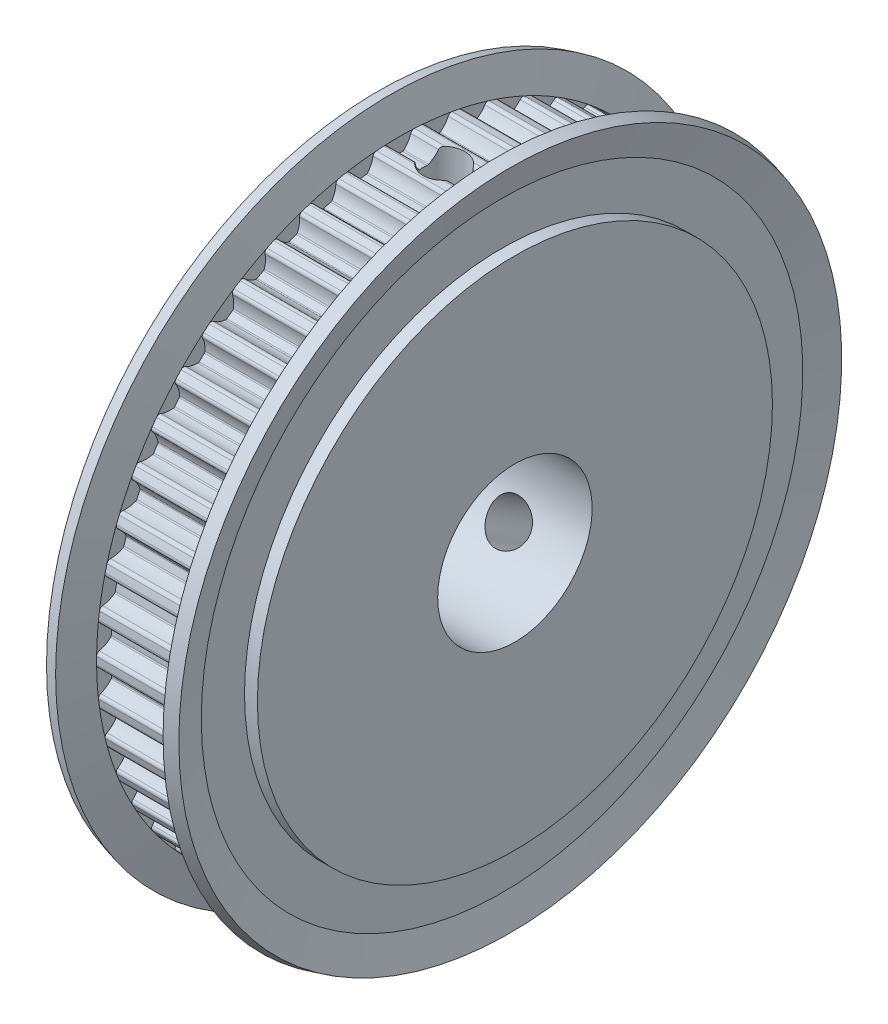
from build123d import *

# Parameters (mm, degrees)
SKETCH_2_W          = 11
SKETCH_2_H          = 6
SKETCH_3_R          = 28.49
CUT_EXTRUDE_1_DEPTH = 7
SKETCH_4_W          = 1.621
SKETCH_4_H          = 23.49


with BuildPart() as part:
    # ｽｹｯﾁ1 → 回転1 (revolve)
    with BuildSketch(Plane.XY):
        Polygon((0, 0), (0, 20), (1, 20), (1, 23.358347502), (0.361521701, 25.741180955), (1.327447527, 26), (2, 23.49), (9, 23.49), (9.672552473, 26), (10.638478299, 25.741180955), (10, 23.358347502), (10, 20), (11, 20), (11, 0), align=None)
    revolve(axis=Axis((11, 0, 0), (-1, 0, 0)))

    # ｽｹｯﾁ2 → ｶｯﾄ - 回転1 (revolve, cut)
    with BuildSketch(Plane.XY):
        with Locations((5.5, 3)):
            Rectangle(SKETCH_2_W, SKETCH_2_H)
    revolve(axis=Axis((11, 0, 0), (-1, 0, 0)), mode=Mode.SUBTRACT)

    # ｽｹｯﾁ3 → ｶｯﾄ - 押し出し1 (cut)
    with BuildSketch(Plane(origin=(2, 0, 0), x_dir=(0, 0, -1), z_dir=(1, 0, 0))):
        Circle(SKETCH_3_R)
        with BuildLine():
            ThreePointArc((-23.488276086, 0.284581247), (-23.49, 7.6e-08), (-23.488276088, -0.284581095))
            ThreePointArc((-23.488276088, -0.284581095), (-23.427611694, -0.455260452), (-23.275160558, -0.553088173))
            ThreePointArc((-23.275160558, -0.553088173), (-22.80663919, -0.73407221), (-22.398920767, -1.027386346))
            ThreePointArc((-22.398920767, -1.027386346), (-22.365264934, -1.07380197), (-22.351481689, -1.129453992))
            ThreePointArc((-22.351481689, -1.129453992), (-22.335838193, -1.405251659), (-22.316791726, -1.680835229))
            ThreePointArc((-22.316791726, -1.680835229), (-22.32349116, -1.737776087), (-22.351064233, -1.788044062))
            ThreePointArc((-22.351064233, -1.788044062), (-22.718805667, -2.130146002), (-23.160949295, -2.368424227))
            ThreePointArc((-23.160949295, -2.368424227), (-23.299937204, -2.484587678), (-23.338731501, -2.661524359))
            ThreePointArc((-23.338731501, -2.661524359), (-23.304774343, -2.944077583), (-23.267396547, -3.226198681))
            ThreePointArc((-23.267396547, -3.226198681), (-23.185818714, -3.387928916), (-23.022308636, -3.465878042))
            ThreePointArc((-23.022308636, -3.465878042), (-22.534798384, -3.586713668), (-22.093532933, -3.826614266))
            ThreePointArc((-22.093532933, -3.826614266), (-22.054325066, -3.868445695), (-22.033675459, -3.921931385))
            ThreePointArc((-22.033675459, -3.921931385), (-21.983588671, -4.19359382), (-21.930152576, -4.464617342))
            ThreePointArc((-21.930152576, -4.464617342), (-21.9296627, -4.521948705), (-21.950718076, -4.575275962))
            ThreePointArc((-21.950718076, -4.575275962), (-22.272683016, -4.960770544), (-22.681476025, -5.252585162))
            ThreePointArc((-22.681476025, -5.252585162), (-22.804808832, -5.385252434), (-22.821121178, -5.56565613))
            ThreePointArc((-22.821121178, -5.56565613), (-22.752018473, -5.841725378), (-22.679576263, -6.116937186))
            ThreePointArc((-22.679576263, -6.116937186), (-22.578371522, -6.267167716), (-22.406381154, -6.324008944))
            ThreePointArc((-22.406381154, -6.324008944), (-21.907570346, -6.382790509), (-21.439716888, -6.565494193))
            ThreePointArc((-21.439716888, -6.565494193), (-21.395575318, -6.60208172), (-21.368385004, -6.652557577))
            ThreePointArc((-21.368385004, -6.652557577), (-21.284644835, -6.915800334), (-21.197661844, -7.177989435))
            ThreePointArc((-21.197661844, -7.177989435), (-21.189990306, -7.234807325), (-21.204195976, -7.290353018))
            ThreePointArc((-21.204195976, -7.290353018), (-21.475306844, -7.713160768), (-21.844302329, -8.053909691))
            ThreePointArc((-21.844302329, -8.053909691), (-21.950035002, -8.200988541), (-21.943608142, -8.38201418))
            ThreePointArc((-21.943608142, -8.38201418), (-21.840449681, -8.647245674), (-21.734085513, -8.911207939))
            ThreePointArc((-21.734085513, -8.911207939), (-21.614849923, -9.047569538), (-21.437091656, -9.082406447))
            ThreePointArc((-21.437091656, -9.082406447), (-20.934846832, -9.078206931), (-20.44778369, -9.200832358))
            ThreePointArc((-20.44778369, -9.200832358), (-20.399404562, -9.231598975), (-20.366102353, -9.278268962))
            ThreePointArc((-20.366102353, -9.278268962), (-20.250029434, -9.528940545), (-20.130871323, -9.778160347))
            ThreePointArc((-20.130871323, -9.778160347), (-20.116139107, -9.833568714), (-20.12327104, -9.890456856))
            ThreePointArc((-20.12327104, -9.890456856), (-20.339252255, -10.343909841), (-20.662630936, -10.728219253))
            ThreePointArc((-20.662630936, -10.728219253), (-20.749096008, -10.887390161), (-20.720031296, -11.066182859))
            ThreePointArc((-20.720031296, -11.066182859), (-20.58444395, -11.31639374), (-20.445835251, -11.564943618))
            ThreePointArc((-20.445835251, -11.564943618), (-20.310449229, -11.685285784), (-20.129726417, -11.697568975))
            ThreePointArc((-20.129726417, -11.697568975), (-19.631968282, -11.630454605), (-19.133376738, -11.691067895))
            ThreePointArc((-19.133376738, -11.691067895), (-19.081523014, -11.715528397), (-19.042634103, -11.757656503))
            ThreePointArc((-19.042634103, -11.757656503), (-18.896058973, -11.991803672), (-18.746604935, -12.22412383))
            ThreePointArc((-18.746604935, -12.22412383), (-18.725044378, -12.277248844), (-18.724990097, -12.33458227))
            ThreePointArc((-18.724990097, -12.33458227), (-18.882435506, -12.811529272), (-19.15509751, -13.233338389))
            ThreePointArc((-19.15509751, -13.233338389), (-19.220931375, -13.402091139), (-19.169687174, -13.575831232))
            ThreePointArc((-19.169687174, -13.575831232), (-19.003809098, -13.807075713), (-18.835141669, -14.036293611))
            ThreePointArc((-18.835141669, -14.036293611), (-18.685740389, -14.138718157), (-18.504903367, -14.128253853))
            ThreePointArc((-18.504903367, -14.128253853), (-18.019481823, -13.999283057), (-17.51722492, -13.996928319))
            ThreePointArc((-17.51722492, -13.996928319), (-17.462714412, -14.014696957), (-17.418852136, -14.051618777))
            ThreePointArc((-17.418852136, -14.051618777), (-17.244086373, -14.265548891), (-17.066693389, -14.477305577))
            ThreePointArc((-17.066693389, -14.477305577), (-17.038644513, -14.527309433), (-17.031404876, -14.584183967))
            ThreePointArc((-17.031404876, -14.584183967), (-17.127831473, -15.077103239), (-17.345476754, -15.529759874))
            ThreePointArc((-17.345476754, -15.529759874), (-17.389641171, -15.705433128), (-17.317025639, -15.871380628))
            ThreePointArc((-17.317025639, -15.871380628), (-17.123472942, -16.080011642), (-16.927406885, -16.286282453))
            ThreePointArc((-16.927406885, -16.286282453), (-16.766346479, -16.369174405), (-16.588246937, -16.336127727))
            ThreePointArc((-16.588246937, -16.336127727), (-16.122817409, -16.147334452), (-15.624816074, -16.082048801))
            ThreePointArc((-15.624816074, -16.082048801), (-15.568508401, -16.092845351), (-15.520364466, -16.123978629))
            ThreePointArc((-15.520364466, -16.123978629), (-15.320164231, -16.314317882), (-15.117629892, -16.502171567))
            ThreePointArc((-15.117629892, -16.502171567), (-15.083535048, -16.548265665), (-15.069224227, -16.603784352))
            ThreePointArc((-15.069224227, -16.603784352), (-15.103111302, -17.104902272), (-15.262307467, -17.581267768))
            ThreePointArc((-15.262307467, -17.581267768), (-15.284105938, -17.761091056), (-15.191264264, -17.91662887))
            ThreePointArc((-15.191264264, -17.91662887), (-14.973089389, -18.099356181), (-14.752716783, -18.279426892))
            ThreePointArc((-14.752716783, -18.279426892), (-14.582537271, -18.341478995), (-14.409983943, -18.286371108))
            ThreePointArc((-14.409983943, -18.286371108), (-13.971886538, -18.040732737), (-13.485994554, -17.913545765))
            ThreePointArc((-13.485994554, -17.913545765), (-13.428777718, -17.917199959), (-13.377111377, -17.942053706))
            ThreePointArc((-13.377111377, -17.942053706), (-13.154633946, -18.105800334), (-12.930152342, -18.266788454))
            ThreePointArc((-12.930152342, -18.266788454), (-12.890549221, -18.308245872), (-12.869392909, -18.361533162))
            ThreePointArc((-12.869392909, -18.361533162), (-12.840206048, -18.86294679), (-12.938442475, -19.355508567))
            ThreePointArc((-12.938442475, -19.355508567), (-12.937531224, -19.536645967), (-12.825927577, -19.679321172))
            ThreePointArc((-12.825927577, -19.679321172), (-12.586571271, -19.833263061), (-12.345367525, -19.98429385))
            ThreePointArc((-12.345367525, -19.98429385), (-12.168752738, -20.024527505), (-12.004466895, -19.948227493))
            ThreePointArc((-12.004466895, -19.948227493), (-11.60061067, -19.649617889), (-11.134490843, -19.462535411))
            ThreePointArc((-11.134490843, -19.462535411), (-11.077267187, -19.45898962), (-11.022893251, -19.477171879))
            ThreePointArc((-11.022893251, -19.477171879), (-10.781647226, -19.611743499), (-10.538758565, -19.743327174))
            ThreePointArc((-10.538758565, -19.743327174), (-10.494271733, -19.779494103), (-10.466603577, -19.829709619))
            ThreePointArc((-10.466603577, -19.829709619), (-10.374803072, -20.323511365), (-10.410530515, -20.824501433))
            ThreePointArc((-10.410530515, -20.824501433), (-10.386923914, -21.004096301), (-10.25831835, -21.131658823))
            ThreePointArc((-10.25831835, -21.131658823), (-10.001555406, -21.254387535), (-9.743324446, -21.373996555))
            ThreePointArc((-9.743324446, -21.373996555), (-9.563059705, -21.391777253), (-9.409632232, -21.295488414))
            ThreePointArc((-9.409632232, -21.295488414), (-9.046386241, -20.94861683), (-8.607389561, -20.704589248))
            ThreePointArc((-8.607389561, -20.704589248), (-8.551061536, -20.69389939), (-8.494837513, -20.705123415))
            ThreePointArc((-8.494837513, -20.705123415), (-8.238627489, -20.808397754), (-7.98116227, -20.908501831))
            ThreePointArc((-7.98116227, -20.908501831), (-7.932493314, -20.938807892), (-7.898749657, -20.985159701))
            ThreePointArc((-7.898749657, -20.985159701), (-7.745783254, -21.463562022), (-7.718438271, -21.965079472))
            ThreePointArc((-7.718438271, -21.965079472), (-7.672508609, -22.140299489), (-7.528929315, -22.250737592))
            ThreePointArc((-7.528929315, -22.250737592), (-7.258809037, -22.34031762), (-6.98762332, -22.426618567))
            ThreePointArc((-6.98762332, -22.426618567), (-6.806551508, -22.421665896), (-6.666402048, -22.306906762))
            ThreePointArc((-6.666402048, -22.306906762), (-6.349494892, -21.917243564), (-5.94454459, -21.620119337))
            ThreePointArc((-5.94454459, -21.620119337), (-5.890000528, -21.602454004), (-5.832813113, -21.606542787))
            ThreePointArc((-5.832813113, -21.606542787), (-5.565679675, -21.676891146), (-5.297698278, -21.743936924))
            ThreePointArc((-5.297698278, -21.743936924), (-5.245614737, -21.767904173), (-5.206327738, -21.809661279))
            ThreePointArc((-5.206327738, -21.809661279), (-4.994607809, -22.265119483), (-4.904621644, -22.759255086))
            ThreePointArc((-4.904621644, -22.759255086), (-4.83709326, -22.927336928), (-4.680804567, -23.018908936))
            ThreePointArc((-4.680804567, -23.018908936), (-4.401586913, -23.073927551), (-4.1217232, -23.125559406))
            ThreePointArc((-4.1217232, -23.125559406), (-3.942699928, -23.097951473), (-3.818038721, -22.966531864))
            ThreePointArc((-3.818038721, -22.966531864), (-3.55246822, -22.540222276), (-3.187950609, -22.19468723))
            ThreePointArc((-3.187950609, -22.19468723), (-3.136050699, -22.170325013), (-3.078801766, -22.167214071))
            ThreePointArc((-3.078801766, -22.167214071), (-2.804957934, -22.203526994), (-2.530686755, -22.236457104))
            ThreePointArc((-2.530686755, -22.236457104), (-2.476009826, -22.253707525), (-2.431798915, -22.29021148))
            ThreePointArc((-2.431798915, -22.29021148), (-2.164664413, -22.715542715), (-2.013456204, -23.194503652))
            ThreePointArc((-2.013456204, -23.194503652), (-1.925394058, -23.352796569), (-1.75886073, -23.424058336))
            ThreePointArc((-1.75886073, -23.424058336), (-1.474949132, -23.443647862), (-1.190821043, -23.45979636))
            ThreePointArc((-1.190821043, -23.45979636), (-1.016669614, -23.409968558), (-0.909462643, -23.263961039))
            ThreePointArc((-0.909462643, -23.263961039), (-0.699417006, -22.807728222), (-0.381080752, -22.419231654))
            ThreePointArc((-0.381080752, -22.419231654), (-0.332643482, -22.388556754), (-0.276235875, -22.378295148))
            ThreePointArc((-0.276235875, -22.378295148), (0, -22.38), (0.276235875, -22.378295148))
            ThreePointArc((0.276235875, -22.378295148), (0.332643535, -22.388556775), (0.381080835, -22.419231733))
            ThreePointArc((0.381080835, -22.419231733), (0.699417036, -22.807728271), (0.909462643, -23.263961039))
            ThreePointArc((0.909462643, -23.263961039), (1.016669756, -23.409968656), (1.190821387, -23.459796342))
            ThreePointArc((1.190821387, -23.459796342), (1.474949475, -23.44364784), (1.758861073, -23.42405831))
            ThreePointArc((1.758861073, -23.42405831), (1.925394186, -23.352796454), (2.013456204, -23.194503652))
            ThreePointArc((2.013456204, -23.194503652), (2.164664436, -22.715542665), (2.431798985, -22.290211395))
            ThreePointArc((2.431798985, -22.290211395), (2.476009727, -22.253707579), (2.53068642, -22.236457142))
            ThreePointArc((2.53068642, -22.236457142), (2.804957767, -22.203527015), (3.078801766, -22.167214071))
            ThreePointArc((3.078801766, -22.167214071), (3.13605076, -22.170325029), (3.187950712, -22.194687305))
            ThreePointArc((3.187950712, -22.194687305), (3.55246826, -22.540222325), (3.818038721, -22.966531864))
            ThreePointArc((3.818038721, -22.966531864), (3.94270008, -23.097951553), (4.121723539, -23.125559346))
            ThreePointArc((4.121723539, -23.125559346), (4.401587249, -23.073927487), (4.680804899, -23.018908868))
            ThreePointArc((4.680804899, -23.018908868), (4.83709337, -22.927336799), (4.904621644, -22.759255086))
            ThreePointArc((4.904621644, -22.759255086), (4.994607826, -22.26511943), (5.206327797, -21.809661185))
            ThreePointArc((5.206327797, -21.809661185), (5.245614783, -21.767904141), (5.297698278, -21.743936924))
            ThreePointArc((5.297698278, -21.743936924), (5.565679675, -21.676891146), (5.832813113, -21.606542787))
            ThreePointArc((5.832813113, -21.606542787), (5.890000585, -21.602454011), (5.944544691, -21.620119392))
            ThreePointArc((5.944544691, -21.620119392), (6.349494934, -21.917243603), (6.666402048, -22.306906762))
            ThreePointArc((6.666402048, -22.306906762), (6.806551674, -22.421665958), (6.987623659, -22.426618461))
            ThreePointArc((6.987623659, -22.426618461), (7.258809367, -22.340317513), (7.528929636, -22.250737483))
            ThreePointArc((7.528929636, -22.250737483), (7.672508702, -22.140299347), (7.718438271, -21.965079472))
            ThreePointArc((7.718438271, -21.965079472), (7.745783265, -21.463561967), (7.898749704, -20.9851596))
            ThreePointArc((7.898749704, -20.9851596), (7.932493355, -20.938807854), (7.98116227, -20.908501831))
            ThreePointArc((7.98116227, -20.908501831), (8.238627489, -20.808397754), (8.494837513, -20.705123415))
            ThreePointArc((8.494837513, -20.705123415), (8.551061588, -20.69389939), (8.607389659, -20.704589287))
            ThreePointArc((8.607389659, -20.704589287), (9.046386283, -20.948616861), (9.409632232, -21.295488414))
            ThreePointArc((9.409632232, -21.295488414), (9.563059873, -21.391777293), (9.743324759, -21.373996412))
            ThreePointArc((9.743324759, -21.373996412), (10.001555715, -21.254387389), (10.258318655, -21.131658675))
            ThreePointArc((10.258318655, -21.131658675), (10.386923989, -21.004096149), (10.410530515, -20.824501433))
            ThreePointArc((10.410530515, -20.824501433), (10.374803075, -20.323511307), (10.466603613, -19.829709507))
            ThreePointArc((10.466603613, -19.829709507), (10.494271771, -19.779494057), (10.538758565, -19.743327174))
            ThreePointArc((10.538758565, -19.743327174), (10.781647226, -19.611743499), (11.022893251, -19.477171879))
            ThreePointArc((11.022893251, -19.477171879), (11.077267243, -19.458989612), (11.134490952, -19.46253544))
            ThreePointArc((11.134490952, -19.46253544), (11.600610719, -19.649617917), (12.004466895, -19.948227493))
            ThreePointArc((12.004466895, -19.948227493), (12.168752914, -20.024527523), (12.345367827, -19.984293663))
            ThreePointArc((12.345367827, -19.984293663), (12.586571564, -19.833262875), (12.825927861, -19.679320987))
            ThreePointArc((12.825927861, -19.679320987), (12.937531279, -19.536645807), (12.938442475, -19.355508567))
            ThreePointArc((12.938442475, -19.355508567), (12.840206044, -18.862946736), (12.869392929, -18.361533055))
            ThreePointArc((12.869392929, -18.361533055), (12.89054925, -18.308245827), (12.930152342, -18.266788454))
            ThreePointArc((12.930152342, -18.266788454), (13.154633946, -18.105800334), (13.377111377, -17.942053706))
            ThreePointArc((13.377111377, -17.942053706), (13.428777772, -17.917199944), (13.485994666, -17.913545779))
            ThreePointArc((13.485994666, -17.913545779), (13.97188659, -18.040732758), (14.409983943, -18.286371108))
            ThreePointArc((14.409983943, -18.286371108), (14.582537451, -18.341478992), (14.752717064, -18.279426666))
            ThreePointArc((14.752717064, -18.279426666), (14.973089474, -18.09935611), (15.191264159, -17.916628959))
            ThreePointArc((15.191264159, -17.916628959), (15.284105923, -17.761091123), (15.262307467, -17.581267768))
            ThreePointArc((15.262307467, -17.581267768), (15.103111293, -17.104902224), (15.069224233, -16.603784253))
            ThreePointArc((15.069224233, -16.603784253), (15.083535069, -16.54826562), (15.117629892, -16.502171567))
            ThreePointArc((15.117629892, -16.502171567), (15.320164108, -16.314317997), (15.520364223, -16.123978863))
            ThreePointArc((15.520364223, -16.123978863), (15.568508299, -16.092845392), (15.624816191, -16.082048801))
            ThreePointArc((15.624816191, -16.082048801), (16.122817465, -16.147334467), (16.588246937, -16.336127727))
            ThreePointArc((16.588246937, -16.336127727), (16.766346658, -16.369174379), (16.927407135, -16.286282193))
            ThreePointArc((16.927407135, -16.286282193), (17.123473018, -16.080011561), (17.317025545, -15.87138073))
            ThreePointArc((17.317025545, -15.87138073), (17.389641166, -15.705433186), (17.345476741, -15.529759855))
            ThreePointArc((17.345476741, -15.529759855), (17.127831452, -15.077103178), (17.03140487, -14.584183861))
            ThreePointArc((17.03140487, -14.584183861), (17.038644529, -14.527309382), (17.066693389, -14.477305577))
            ThreePointArc((17.066693389, -14.477305577), (17.244086373, -14.265548891), (17.418852136, -14.051618777))
            ThreePointArc((17.418852136, -14.051618777), (17.462714456, -14.014696932), (17.517225021, -13.996928307))
            ThreePointArc((17.517225021, -13.996928307), (18.019481873, -13.999283064), (18.504903367, -14.128253853))
            ThreePointArc((18.504903367, -14.128253853), (18.685740562, -14.138718108), (18.835141884, -14.036293321))
            ThreePointArc((18.835141884, -14.036293321), (19.003809164, -13.807075623), (19.169687095, -13.575831345))
            ThreePointArc((19.169687095, -13.575831345), (19.220931378, -13.402091219), (19.155097524, -13.233338406))
            ThreePointArc((19.155097524, -13.233338406), (18.882435489, -12.811529237), (18.724990077, -12.334582171))
            ThreePointArc((18.724990077, -12.334582171), (18.725044388, -12.277248794), (18.746604935, -12.22412383))
            ThreePointArc((18.746604935, -12.22412383), (18.896058973, -11.991803672), (19.042634103, -11.757656503))
            ThreePointArc((19.042634103, -11.757656503), (19.08152302, -11.715528392), (19.133376752, -11.691067892))
            ThreePointArc((19.133376752, -11.691067892), (19.631968289, -11.630454605), (20.129726417, -11.697568975))
            ThreePointArc((20.129726417, -11.697568975), (20.310449176, -11.685285807), (20.445835194, -11.564943719))
            ThreePointArc((20.445835194, -11.564943719), (20.584443886, -11.316393855), (20.720031227, -11.06618299))
            ThreePointArc((20.720031227, -11.06618299), (20.74909602, -10.887390234), (20.662630936, -10.728219253))
            ThreePointArc((20.662630936, -10.728219253), (20.339252224, -10.343909792), (20.123271004, -9.890456745))
            ThreePointArc((20.123271004, -9.890456745), (20.116139111, -9.833568655), (20.130871323, -9.778160347))
            ThreePointArc((20.130871323, -9.778160347), (20.250029434, -9.528940545), (20.366102353, -9.278268962))
            ThreePointArc((20.366102353, -9.278268962), (20.399404569, -9.231598969), (20.447783708, -9.200832351))
            ThreePointArc((20.447783708, -9.200832351), (20.934846841, -9.07820693), (21.437091656, -9.082406447))
            ThreePointArc((21.437091656, -9.082406447), (21.614849878, -9.047569564), (21.734085474, -8.911208034))
            ThreePointArc((21.734085474, -8.911208034), (21.840449634, -8.647245791), (21.943608089, -8.382014318))
            ThreePointArc((21.943608089, -8.382014318), (21.95003502, -8.2009886), (21.844302308, -8.053909676))
            ThreePointArc((21.844302308, -8.053909676), (21.475306798, -7.713160714), (21.204195927, -7.290352915))
            ThreePointArc((21.204195927, -7.290352915), (21.189990302, -7.234807268), (21.197661844, -7.177989435))
            ThreePointArc((21.197661844, -7.177989435), (21.284644835, -6.915800334), (21.368385004, -6.652557577))
            ThreePointArc((21.368385004, -6.652557577), (21.395575322, -6.602081715), (21.439716897, -6.565494187))
            ThreePointArc((21.439716897, -6.565494187), (21.907570351, -6.382790507), (22.406381154, -6.324008944))
            ThreePointArc((22.406381154, -6.324008944), (22.578371483, -6.267167746), (22.679576238, -6.11693728))
            ThreePointArc((22.679576238, -6.11693728), (22.752018443, -5.841725496), (22.821121143, -5.565656274))
            ThreePointArc((22.821121143, -5.565656274), (22.804808858, -5.385252491), (22.681476005, -5.252585151))
            ThreePointArc((22.681476005, -5.252585151), (22.272682965, -4.960770497), (21.950718013, -4.575275864))
            ThreePointArc((21.950718013, -4.575275864), (21.929662689, -4.521948648), (21.930152576, -4.464617342))
            ThreePointArc((21.930152576, -4.464617342), (21.983588671, -4.19359382), (22.033675459, -3.921931385))
            ThreePointArc((22.033675459, -3.921931385), (22.05432507, -3.868445689), (22.093532945, -3.826614258))
            ThreePointArc((22.093532945, -3.826614258), (22.53479839, -3.586713666), (23.022308636, -3.465878042))
            ThreePointArc((23.022308636, -3.465878042), (23.185818679, -3.387928949), (23.267396534, -3.226198776))
            ThreePointArc((23.267396534, -3.226198776), (23.304774328, -2.944077704), (23.338731485, -2.661524505))
            ThreePointArc((23.338731485, -2.661524505), (23.299937243, -2.484587741), (23.160949295, -2.368424227))
            ThreePointArc((23.160949295, -2.368424227), (22.718805623, -2.13014597), (22.351064164, -1.78804398))
            ThreePointArc((22.351064164, -1.78804398), (22.323491195, -1.737776196), (22.3167917, -1.680835565))
            ThreePointArc((22.3167917, -1.680835565), (22.335838182, -1.405251827), (22.351481689, -1.129453992))
            ThreePointArc((22.351481689, -1.129453992), (22.365264935, -1.073801967), (22.398920772, -1.027386341))
            ThreePointArc((22.398920772, -1.027386341), (22.806639193, -0.734072209), (23.275160558, -0.553088173))
            ThreePointArc((23.275160558, -0.553088173), (23.427611669, -0.455260484), (23.488276087, -0.284581175))
            ThreePointArc((23.488276087, -0.284581175), (23.49, 1.98e-07), (23.488276083, 0.284581572))
            ThreePointArc((23.488276083, 0.284581572), (23.427611546, 0.455260639), (23.275160558, 0.553088173))
            ThreePointArc((23.275160558, 0.553088173), (22.806639138, 0.734072239), (22.39892068, 1.027386427))
            ThreePointArc((22.39892068, 1.027386427), (22.365264909, 1.073802024), (22.351481689, 1.129453992))
            ThreePointArc((22.351481689, 1.129453992), (22.335838182, 1.405251827), (22.3167917, 1.680835565))
            ThreePointArc((22.3167917, 1.680835565), (22.323491214, 1.737776256), (22.351064244, 1.788044077))
            ThreePointArc((22.351064244, 1.788044077), (22.718805675, 2.130146007), (23.160949295, 2.368424227))
            ThreePointArc((23.160949295, 2.368424227), (23.299937222, 2.484587706), (23.338731494, 2.661524425))
            ThreePointArc((23.338731494, 2.661524425), (23.304774309, 2.944077853), (23.267396481, 3.226199153))
            ThreePointArc((23.267396481, 3.226199153), (23.185818543, 3.387929082), (23.022308636, 3.465878042))
            ThreePointArc((23.022308636, 3.465878042), (22.534798391, 3.586713665), (22.093532946, 3.826614257))
            ThreePointArc((22.093532946, 3.826614257), (22.05432507, 3.868445688), (22.033675459, 3.921931385))
            ThreePointArc((22.033675459, 3.921931385), (21.983588671, 4.19359382), (21.930152576, 4.464617342))
            ThreePointArc((21.930152576, 4.464617342), (21.9296627, 4.521948707), (21.950718078, 4.575275965))
            ThreePointArc((21.950718078, 4.575275965), (22.272683017, 4.960770545), (22.681476025, 5.252585162))
            ThreePointArc((22.681476025, 5.252585162), (22.804808848, 5.385252468), (22.82112116, 5.565656204))
            ThreePointArc((22.82112116, 5.565656204), (22.752018464, 5.841725415), (22.679576263, 6.116937186))
            ThreePointArc((22.679576263, 6.116937186), (22.578371522, 6.267167716), (22.406381154, 6.324008944))
            ThreePointArc((22.406381154, 6.324008944), (21.907570286, 6.382790524), (21.439716778, 6.565494252))
            ThreePointArc((21.439716778, 6.565494252), (21.395575279, 6.602081768), (21.368385004, 6.652557577))
            ThreePointArc((21.368385004, 6.652557577), (21.284644835, 6.915800334), (21.197661844, 7.177989435))
            ThreePointArc((21.197661844, 7.177989435), (21.189990306, 7.234807328), (21.204195978, 7.290353024))
            ThreePointArc((21.204195978, 7.290353024), (21.475306846, 7.713160771), (21.844302329, 8.053909691))
            ThreePointArc((21.844302329, 8.053909691), (21.950035013, 8.200988578), (21.943608115, 8.382014251))
            ThreePointArc((21.943608115, 8.382014251), (21.840449579, 8.647245931), (21.734085332, 8.91120838))
            ThreePointArc((21.734085332, 8.91120838), (21.614849717, 9.047569658), (21.437091656, 9.082406447))
            ThreePointArc((21.437091656, 9.082406447), (20.934846778, 9.078206937), (20.447783589, 9.200832397))
            ThreePointArc((20.447783589, 9.200832397), (20.399404523, 9.231599013), (20.366102353, 9.278268962))
            ThreePointArc((20.366102353, 9.278268962), (20.250029434, 9.528940545), (20.130871323, 9.778160347))
            ThreePointArc((20.130871323, 9.778160347), (20.116139106, 9.833568719), (20.123271043, 9.890456866))
            ThreePointArc((20.123271043, 9.890456866), (20.339252258, 10.343909846), (20.662630936, 10.728219253))
            ThreePointArc((20.662630936, 10.728219253), (20.749096014, 10.887390198), (20.720031261, 11.066182926))
            ThreePointArc((20.720031261, 11.066182926), (20.584443817, 11.316393982), (20.445835016, 11.564944033))
            ThreePointArc((20.445835016, 11.564944033), (20.310449009, 11.685285876), (20.129726417, 11.697568975))
            ThreePointArc((20.129726417, 11.697568975), (19.631968294, 11.630454605), (19.133376761, 11.691067889))
            ThreePointArc((19.133376761, 11.691067889), (19.081523024, 11.715528389), (19.042634103, 11.757656503))
            ThreePointArc((19.042634103, 11.757656503), (18.896059063, 11.991803529), (18.746605119, 12.224123547))
            ThreePointArc((18.746605119, 12.224123547), (18.725044409, 12.277248686), (18.7249901, 12.334582286))
            ThreePointArc((18.7249901, 12.334582286), (18.88243551, 12.811529279), (19.15509751, 13.233338389))
            ThreePointArc((19.15509751, 13.233338389), (19.220931376, 13.402091172), (19.169687136, 13.575831286))
            ThreePointArc((19.169687136, 13.575831286), (19.003809079, 13.80707574), (18.835141669, 14.036293611))
            ThreePointArc((18.835141669, 14.036293611), (18.685740389, 14.138718157), (18.504903367, 14.128253853))
            ThreePointArc((18.504903367, 14.128253853), (18.01948188, 13.999283065), (17.517225035, 13.996928305))
            ThreePointArc((17.517225035, 13.996928305), (17.462714462, 14.014696929), (17.418852136, 14.051618777))
            ThreePointArc((17.418852136, 14.051618777), (17.244086481, 14.265548761), (17.066693607, 14.47730532))
            ThreePointArc((17.066693607, 14.47730532), (17.038644566, 14.527309271), (17.031404876, 14.584183964))
            ThreePointArc((17.031404876, 14.584183964), (17.127831472, 15.077103237), (17.345476754, 15.529759874))
            ThreePointArc((17.345476754, 15.529759874), (17.389641168, 15.705433161), (17.317025594, 15.871380677))
            ThreePointArc((17.317025594, 15.871380677), (17.123472919, 16.080011666), (16.927406885, 16.286282453))
            ThreePointArc((16.927406885, 16.286282453), (16.766346479, 16.369174405), (16.588246937, 16.336127727))
            ThreePointArc((16.588246937, 16.336127727), (16.122817466, 16.147334467), (15.624816192, 16.082048801))
            ThreePointArc((15.624816192, 16.082048801), (15.568508456, 16.092845329), (15.520364466, 16.123978629))
            ThreePointArc((15.520364466, 16.123978629), (15.320164108, 16.314317997), (15.117629644, 16.502171795))
            ThreePointArc((15.117629644, 16.502171795), (15.083534975, 16.548265818), (15.069224227, 16.603784355))
            ThreePointArc((15.069224227, 16.603784355), (15.103111303, 17.104902274), (15.262307467, 17.581267768))
            ThreePointArc((15.262307467, 17.581267768), (15.284105932, 17.761091083), (15.19126422, 17.916628907))
            ThreePointArc((15.19126422, 17.916628907), (14.973089367, 18.099356199), (14.752716783, 18.279426892))
            ThreePointArc((14.752716783, 18.279426892), (14.582537271, 18.341478995), (14.409983943, 18.286371108))
            ThreePointArc((14.409983943, 18.286371108), (13.971886596, 18.04073276), (13.485994678, 17.913545781))
            ThreePointArc((13.485994678, 17.913545781), (13.428777778, 17.917199943), (13.377111377, 17.942053706))
            ThreePointArc((13.377111377, 17.942053706), (13.15463381, 18.105800433), (12.930152067, 18.266788649))
            ThreePointArc((12.930152067, 18.266788649), (12.890549134, 18.308246008), (12.869392912, 18.361533147))
            ThreePointArc((12.869392912, 18.361533147), (12.840206047, 18.862946782), (12.938442475, 19.355508567))
            ThreePointArc((12.938442475, 19.355508567), (12.937531209, 19.536646009), (12.825927502, 19.679321221))
            ThreePointArc((12.825927502, 19.679321221), (12.586571435, 19.833262957), (12.345367931, 19.984293599))
            ThreePointArc((12.345367931, 19.984293599), (12.168752975, 20.02452753), (12.004466895, 19.948227493))
            ThreePointArc((12.004466895, 19.948227493), (11.600610721, 19.649617918), (11.134490958, 19.462535441))
            ThreePointArc((11.134490958, 19.462535441), (11.077267246, 19.458989612), (11.022893251, 19.477171879))
            ThreePointArc((11.022893251, 19.477171879), (10.781647079, 19.611743581), (10.538758268, 19.743327333))
            ThreePointArc((10.538758268, 19.743327333), (10.494271632, 19.779494223), (10.466603584, 19.829709597))
            ThreePointArc((10.466603584, 19.829709597), (10.374803072, 20.323511354), (10.410530515, 20.824501433))
            ThreePointArc((10.410530515, 20.824501433), (10.386923872, 21.004096384), (10.258318182, 21.131658905))
            ThreePointArc((10.258318182, 21.131658905), (10.001555321, 21.254387574), (9.743324446, 21.373996555))
            ThreePointArc((9.743324446, 21.373996555), (9.563059705, 21.391777253), (9.409632232, 21.295488414))
            ThreePointArc((9.409632232, 21.295488414), (9.046386289, 20.948616865), (8.607389671, 20.704589292))
            ThreePointArc((8.607389671, 20.704589292), (8.551061595, 20.69389939), (8.494837513, 20.705123415))
            ThreePointArc((8.494837513, 20.705123415), (8.238627332, 20.808397816), (7.981161955, 20.908501951))
            ThreePointArc((7.981161955, 20.908501951), (7.932493198, 20.938808), (7.898749666, 20.985159682))
            ThreePointArc((7.898749666, 20.985159682), (7.745783256, 21.463562012), (7.718438271, 21.965079472))
            ThreePointArc((7.718438271, 21.965079472), (7.672508584, 22.140299526), (7.52892923, 22.25073762))
            ThreePointArc((7.52892923, 22.25073762), (7.258808994, 22.340317634), (6.98762332, 22.426618567))
            ThreePointArc((6.98762332, 22.426618567), (6.806551508, 22.421665896), (6.666402048, 22.306906762))
            ThreePointArc((6.666402048, 22.306906762), (6.349494938, 21.917243607), (5.944544701, 21.620119398))
            ThreePointArc((5.944544701, 21.620119398), (5.890000591, 21.602454012), (5.832813113, 21.606542787))
            ThreePointArc((5.832813113, 21.606542787), (5.565679838, 21.676891104), (5.297698606, 21.743936844))
            ThreePointArc((5.297698606, 21.743936844), (5.245614884, 21.767904068), (5.20632775, 21.80966126))
            ThreePointArc((5.20632775, 21.80966126), (4.994607812, 22.265119472), (4.904621644, 22.759255086))
            ThreePointArc((4.904621644, 22.759255086), (4.83709323, 22.927336961), (4.68080448, 23.018908954))
            ThreePointArc((4.68080448, 23.018908954), (4.401586869, 23.07392756), (4.1217232, 23.125559406))
            ThreePointArc((4.1217232, 23.125559406), (3.942699925, 23.097951472), (3.818038719, 22.966531859))
            ThreePointArc((3.818038719, 22.966531859), (3.55246826, 22.540222325), (3.187950716, 22.194687308))
            ThreePointArc((3.187950716, 22.194687308), (3.136050763, 22.170325029), (3.078801766, 22.167214071))
            ThreePointArc((3.078801766, 22.167214071), (2.804957934, 22.203526994), (2.530686755, 22.236457104))
            ThreePointArc((2.530686755, 22.236457104), (2.476009843, 22.253707516), (2.431798938, 22.290211451))
            ThreePointArc((2.431798938, 22.290211451), (2.164664421, 22.715542698), (2.013456204, 23.194503652))
            ThreePointArc((2.013456204, 23.194503652), (1.925394027, 23.352796597), (1.758860646, 23.424058342))
            ThreePointArc((1.758860646, 23.424058342), (1.474949328, 23.443647849), (1.19082152, 23.459796336))
            ThreePointArc((1.19082152, 23.459796336), (1.01666981, 23.409968694), (0.909462643, 23.263961039))
            ThreePointArc((0.909462643, 23.263961039), (0.699417039, 22.807728276), (0.381080844, 22.419231741))
            ThreePointArc((0.381080844, 22.419231741), (0.332643549, 22.38855678), (0.276235892, 22.378295148))
            ThreePointArc((0.276235892, 22.378295148), (8e-09, 22.38), (-0.276235875, 22.378295148))
            ThreePointArc((-0.276235875, 22.378295148), (-0.332643507, 22.388556764), (-0.381080791, 22.419231691))
            ThreePointArc((-0.381080791, 22.419231691), (-0.69941702, 22.807728245), (-0.909462643, 23.263961039))
            ThreePointArc((-0.909462643, 23.263961039), (-1.016669797, 23.409968685), (-1.190821488, 23.459796337))
            ThreePointArc((-1.190821488, 23.459796337), (-1.474949526, 23.443647837), (-1.758861073, 23.42405831))
            ThreePointArc((-1.758861073, 23.42405831), (-1.925394186, 23.352796454), (-2.013456204, 23.194503652))
            ThreePointArc((-2.013456204, 23.194503652), (-2.164664415, 22.715542712), (-2.431798919, 22.290211474))
            ThreePointArc((-2.431798919, 22.290211474), (-2.476009682, 22.253707603), (-2.53068642, 22.236457142))
            ThreePointArc((-2.53068642, 22.236457142), (-2.804957767, 22.203527015), (-3.078801766, 22.167214071))
            ThreePointArc((-3.078801766, 22.167214071), (-3.136050744, 22.170325024), (-3.187950684, 22.194687285))
            ThreePointArc((-3.187950684, 22.194687285), (-3.552468249, 22.540222312), (-3.818038721, 22.966531864))
            ThreePointArc((-3.818038721, 22.966531864), (-3.94270007, 23.097951547), (-4.121723515, 23.12555935))
            ThreePointArc((-4.121723515, 23.12555935), (-4.401587237, 23.07392749), (-4.680804899, 23.018908868))
            ThreePointArc((-4.680804899, 23.018908868), (-4.83709337, 22.927336799), (-4.904621644, 22.759255086))
            ThreePointArc((-4.904621644, 22.759255086), (-4.994607809, 22.265119482), (-5.206327739, 21.809661277))
            ThreePointArc((-5.206327739, 21.809661277), (-5.245614738, 21.767904172), (-5.297698278, 21.743936924))
            ThreePointArc((-5.297698278, 21.743936924), (-5.565679675, 21.676891146), (-5.832813113, 21.606542787))
            ThreePointArc((-5.832813113, 21.606542787), (-5.890000581, 21.602454011), (-5.944544684, 21.620119388))
            ThreePointArc((-5.944544684, 21.620119388), (-6.349494931, 21.9172436), (-6.666402048, 22.306906762))
            ThreePointArc((-6.666402048, 22.306906762), (-6.806551658, 22.421665952), (-6.987623626, 22.426618472))
            ThreePointArc((-6.987623626, 22.426618472), (-7.25880935, 22.340317518), (-7.528929636, 22.250737483))
            ThreePointArc((-7.528929636, 22.250737483), (-7.672508702, 22.140299347), (-7.718438271, 21.965079472))
            ThreePointArc((-7.718438271, 21.965079472), (-7.745783255, 21.463562017), (-7.898749661, 20.985159693))
            ThreePointArc((-7.898749661, 20.985159693), (-7.932493317, 20.938807889), (-7.98116227, 20.908501831))
            ThreePointArc((-7.98116227, 20.908501831), (-8.238627489, 20.808397754), (-8.494837513, 20.705123415))
            ThreePointArc((-8.494837513, 20.705123415), (-8.551061584, 20.69389939), (-8.60738965, 20.704589284))
            ThreePointArc((-8.60738965, 20.704589284), (-9.04638628, 20.948616858), (-9.409632232, 21.295488414))
            ThreePointArc((-9.409632232, 21.295488414), (-9.563059861, 21.39177729), (-9.743324737, 21.373996422))
            ThreePointArc((-9.743324737, 21.373996422), (-10.001555704, 21.254387394), (-10.258318655, 21.131658675))
            ThreePointArc((-10.258318655, 21.131658675), (-10.386923989, 21.004096149), (-10.410530515, 20.824501433))
            ThreePointArc((-10.410530515, 20.824501433), (-10.374803073, 20.323511343), (-10.466603591, 19.829709576))
            ThreePointArc((-10.466603591, 19.829709576), (-10.494271747, 19.779494085), (-10.538758565, 19.743327174))
            ThreePointArc((-10.538758565, 19.743327174), (-10.781647226, 19.611743499), (-11.022893251, 19.477171879))
            ThreePointArc((-11.022893251, 19.477171879), (-11.077267239, 19.458989613), (-11.134490945, 19.462535438))
            ThreePointArc((-11.134490945, 19.462535438), (-11.600610716, 19.649617915), (-12.004466895, 19.948227493))
            ThreePointArc((-12.004466895, 19.948227493), (-12.168752897, 20.024527521), (-12.345367797, 19.984293682))
            ThreePointArc((-12.345367797, 19.984293682), (-12.586571549, 19.833262884), (-12.825927861, 19.679320987))
            ThreePointArc((-12.825927861, 19.679320987), (-12.937531279, 19.536645807), (-12.938442475, 19.355508567))
            ThreePointArc((-12.938442475, 19.355508567), (-12.840206046, 18.862946769), (-12.869392917, 18.361533121))
            ThreePointArc((-12.869392917, 18.361533121), (-12.890549232, 18.308245855), (-12.930152342, 18.266788454))
            ThreePointArc((-12.930152342, 18.266788454), (-13.154634083, 18.105800235), (-13.377111647, 17.942053505))
            ThreePointArc((-13.377111647, 17.942053505), (-13.428777931, 17.917199903), (-13.485994657, 17.913545778))
            ThreePointArc((-13.485994657, 17.913545778), (-13.971886586, 18.040732756), (-14.409983943, 18.286371108))
            ThreePointArc((-14.409983943, 18.286371108), (-14.582537433, 18.341478992), (-14.752717036, 18.279426688))
            ThreePointArc((-14.752717036, 18.279426688), (-14.973089644, 18.099355969), (-15.191264522, 17.916628651))
            ThreePointArc((-15.191264522, 17.916628651), (-15.284105973, 17.76109089), (-15.262307467, 17.581267768))
            ThreePointArc((-15.262307467, 17.581267768), (-15.103111302, 17.104902271), (-15.069224227, 16.603784349))
            ThreePointArc((-15.069224227, 16.603784349), (-15.083535049, 16.548265664), (-15.117629892, 16.502171567))
            ThreePointArc((-15.117629892, 16.502171567), (-15.320164354, 16.314317766), (-15.520364709, 16.123978395))
            ThreePointArc((-15.520364709, 16.123978395), (-15.568508608, 16.092845269), (-15.624816181, 16.082048801))
            ThreePointArc((-15.624816181, 16.082048801), (-16.122817461, 16.147334465), (-16.588246937, 16.336127727))
            ThreePointArc((-16.588246937, 16.336127727), (-16.766346642, 16.369174381), (-16.927407113, 16.286282216))
            ThreePointArc((-16.927407113, 16.286282216), (-17.123473171, 16.080011398), (-17.317025868, 15.871380378))
            ThreePointArc((-17.317025868, 15.871380378), (-17.389641185, 15.705432959), (-17.345476754, 15.529759874))
            ThreePointArc((-17.345476754, 15.529759874), (-17.12783147, 15.077103231), (-17.031404875, 14.584183951))
            ThreePointArc((-17.031404875, 14.584183951), (-17.038644515, 14.527309425), (-17.066693389, 14.477305577))
            ThreePointArc((-17.066693389, 14.477305577), (-17.244086266, 14.26554902), (-17.418851925, 14.05161904))
            ThreePointArc((-17.418851925, 14.05161904), (-17.462714302, 14.014697018), (-17.517225006, 13.996928309))
            ThreePointArc((-17.517225006, 13.996928309), (-18.019481866, 13.999283063), (-18.504903367, 14.128253853))
            ThreePointArc((-18.504903367, 14.128253853), (-18.685740547, 14.138718112), (-18.835141865, 14.036293347))
            ThreePointArc((-18.835141865, 14.036293347), (-19.003809295, 13.807075443), (-19.16968737, 13.575830955))
            ThreePointArc((-19.16968737, 13.575830955), (-19.220931367, 13.402090969), (-19.15509751, 13.233338389))
            ThreePointArc((-19.15509751, 13.233338389), (-18.882435504, 12.811529267), (-18.724990094, 12.334582259))
            ThreePointArc((-18.724990094, 12.334582259), (-18.725044379, 12.277248838), (-18.746604935, 12.22412383))
            ThreePointArc((-18.746604935, 12.22412383), (-18.896058973, 11.991803672), (-19.042634103, 11.757656503))
            ThreePointArc((-19.042634103, 11.757656503), (-19.081523014, 11.715528397), (-19.133376737, 11.691067896))
            ThreePointArc((-19.133376737, 11.691067896), (-19.631968282, 11.630454605), (-20.129726417, 11.697568975))
            ThreePointArc((-20.129726417, 11.697568975), (-20.310449161, 11.685285813), (-20.445835178, 11.564943747))
            ThreePointArc((-20.445835178, 11.564943747), (-20.584443994, 11.31639366), (-20.720031451, 11.066182569))
            ThreePointArc((-20.720031451, 11.066182569), (-20.74909598, 10.887389999), (-20.662630936, 10.728219253))
            ThreePointArc((-20.662630936, 10.728219253), (-20.33925225, 10.343909833), (-20.123271034, 9.890456837))
            ThreePointArc((-20.123271034, 9.890456837), (-20.116139107, 9.833568703), (-20.130871323, 9.778160347))
            ThreePointArc((-20.130871323, 9.778160347), (-20.250029362, 9.528940698), (-20.366102214, 9.278269269))
            ThreePointArc((-20.366102214, 9.278269269), (-20.399404439, 9.231599092), (-20.447783688, 9.200832359))
            ThreePointArc((-20.447783688, 9.200832359), (-20.934846831, 9.078206931), (-21.437091656, 9.082406447))
            ThreePointArc((-21.437091656, 9.082406447), (-21.614849857, 9.047569576), (-21.734085455, 8.911208079))
            ThreePointArc((-21.734085455, 8.911208079), (-21.840449713, 8.647245592), (-21.943608259, 8.382013873))
            ThreePointArc((-21.943608259, 8.382013873), (-21.950034955, 8.200988384), (-21.844302329, 8.053909691))
            ThreePointArc((-21.844302329, 8.053909691), (-21.475306842, 7.713160766), (-21.204195973, 7.290353013))
            ThreePointArc((-21.204195973, 7.290353013), (-21.189990306, 7.234807322), (-21.197661844, 7.177989435))
            ThreePointArc((-21.197661844, 7.177989435), (-21.284644783, 6.915800494), (-21.368384904, 6.652557899))
            ThreePointArc((-21.368384904, 6.652557899), (-21.395575208, 6.602081854), (-21.439716879, 6.565494197))
            ThreePointArc((-21.439716879, 6.565494197), (-21.907570341, 6.38279051), (-22.406381154, 6.324008944))
            ThreePointArc((-22.406381154, 6.324008944), (-22.578371461, 6.267167762), (-22.679576223, 6.116937333))
            ThreePointArc((-22.679576223, 6.116937333), (-22.752018495, 5.841725292), (-22.821121256, 5.565655811))
            ThreePointArc((-22.821121256, 5.565655811), (-22.804808765, 5.385252283), (-22.681476025, 5.252585162))
            ThreePointArc((-22.681476025, 5.252585162), (-22.272683016, 4.960770545), (-21.950718077, 4.575275964))
            ThreePointArc((-21.950718077, 4.575275964), (-21.9296627, 4.521948706), (-21.930152576, 4.464617342))
            ThreePointArc((-21.930152576, 4.464617342), (-21.983588671, 4.19359382), (-22.033675459, 3.921931385))
            ThreePointArc((-22.033675459, 3.921931385), (-22.054325064, 3.868445699), (-22.093532926, 3.826614271))
            ThreePointArc((-22.093532926, 3.826614271), (-22.534798379, 3.58671367), (-23.022308636, 3.465878042))
            ThreePointArc((-23.022308636, 3.465878042), (-23.185818657, 3.38792897), (-23.267396525, 3.226198836))
            ThreePointArc((-23.267396525, 3.226198836), (-23.304774324, 2.944077734), (-23.338731485, 2.661524505))
            ThreePointArc((-23.338731485, 2.661524505), (-23.299937243, 2.484587741), (-23.160949295, 2.368424227))
            ThreePointArc((-23.160949295, 2.368424227), (-22.718805672, 2.130146005), (-22.351064239, 1.78804407))
            ThreePointArc((-22.351064239, 1.78804407), (-22.323491213, 1.737776253), (-22.3167917, 1.680835565))
            ThreePointArc((-22.3167917, 1.680835565), (-22.335838172, 1.405251995), (-22.351481672, 1.129454328))
            ThreePointArc((-22.351481672, 1.129454328), (-22.36526486, 1.073802128), (-22.39892076, 1.027386353))
            ThreePointArc((-22.39892076, 1.027386353), (-22.806639185, 0.734072213), (-23.275160558, 0.553088173))
            ThreePointArc((-23.275160558, 0.553088173), (-23.427611646, 0.455260512), (-23.488276086, 0.284581247))
        make_face(mode=Mode.SUBTRACT)
    extrude(amount=CUT_EXTRUDE_1_DEPTH, mode=Mode.SUBTRACT)

    # ｽｹｯﾁ4 → ｶｯﾄ - 回転2 (revolve, cut)
    with BuildSketch(Plane(origin=(5.5, 0, 0), x_dir=(0, 0, -1), z_dir=(1, 0, 0))):
        with Locations((0.8105, 11.745)):
            Rectangle(SKETCH_4_W, SKETCH_4_H)
    revolve(axis=Axis((5.5, 0, 0), (0, 1, 0)), mode=Mode.SUBTRACT)

    # ｽｹｯﾁ5 → ｶｯﾄ - 回転3 (revolve, cut)
    with BuildSketch(Plane(origin=(5.5, 0, 0), x_dir=(0, 0, -1), z_dir=(1, 0, 0))):
        Polygon((19.83326297, -12.586571414), (18.964687735, -13.955226981), (-0.868575235, -1.368655567), (0, 0), align=None)
    revolve(axis=Axis((5.5, 0, 0), (0, -0.535826795, -0.844327926)), mode=Mode.SUBTRACT)


solid = part.part
